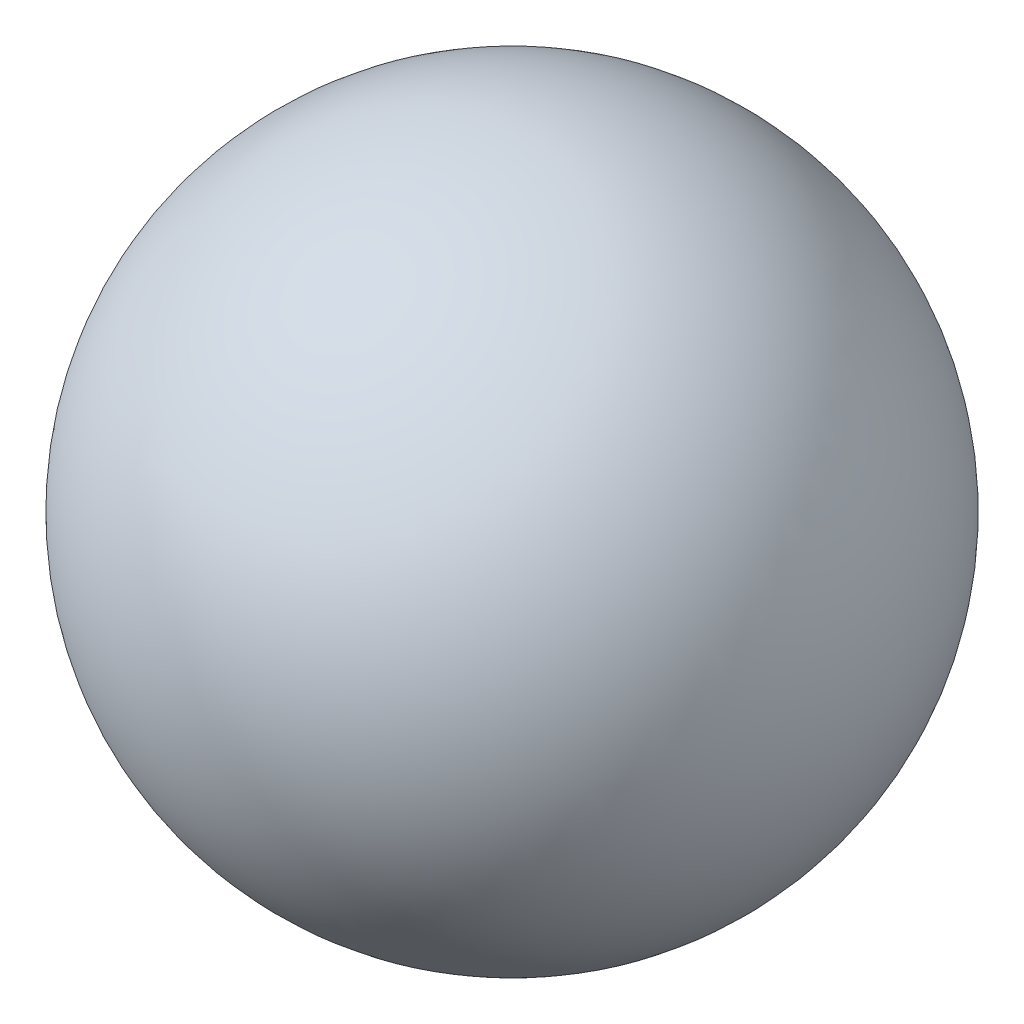
from build123d import *


with BuildPart() as part:
    # ｽｹｯﾁ1 → 回転1 (revolve)
    with BuildSketch(Plane.XY):
        with BuildLine():
            ThreePointArc((0, 125), (125, 0), (0, -125))
            Line((0, -125), (0, 125))
        make_face()
    revolve(axis=Axis((0, 125, 0), (0, -1, 0)))


solid = part.part
